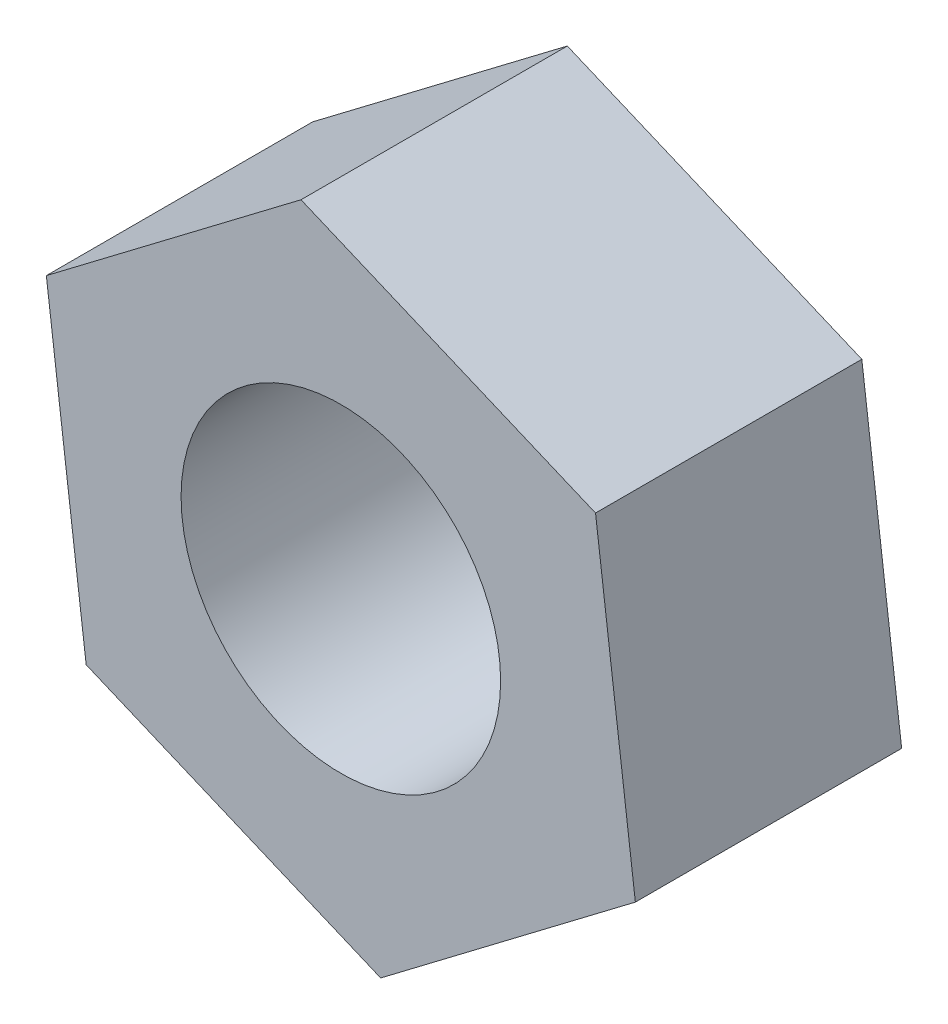
from build123d import *

# Parameters (mm, degrees)
SKETCH1_R           = 3
BOSS_EXTRUDE1_DEPTH = 5


with BuildPart() as part:
    # Sketch1 → Boss-Extrude1 (new body)
    with BuildSketch(Plane.XY):
        Polygon((4.781664284, 3.624318788), (-0.74792, 5.953202136), (-5.529584284, 2.328883348), (-4.781664284, -3.624318788), (0.74792, -5.953202136), (5.529584284, -2.328883348), align=None)
        Circle(SKETCH1_R, mode=Mode.SUBTRACT)
    extrude(amount=BOSS_EXTRUDE1_DEPTH)


solid = part.part
